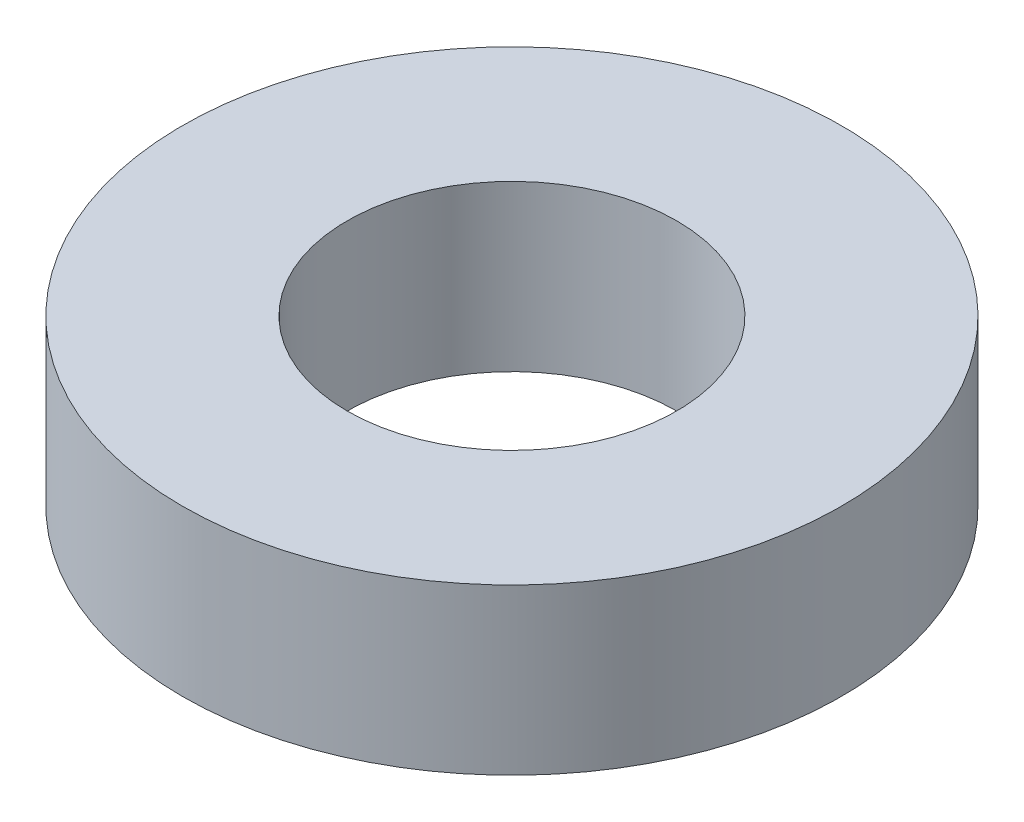
from build123d import *

# Parameters (mm, degrees)
SKETCH1_R           = 3.175
SKETCH1_R_2         = 1.5875
BOSS_EXTRUDE1_DEPTH = 0.79375


with BuildPart() as part:
    # Sketch1 → Boss-Extrude1 (new body, symmetric)
    with BuildSketch(Plane(origin=(0, 0, 0), x_dir=(1, 0, 0), z_dir=(0, 1, 0))):
        Circle(SKETCH1_R)
        Circle(SKETCH1_R_2, mode=Mode.SUBTRACT)
    extrude(amount=BOSS_EXTRUDE1_DEPTH, both=True)


solid = part.part
